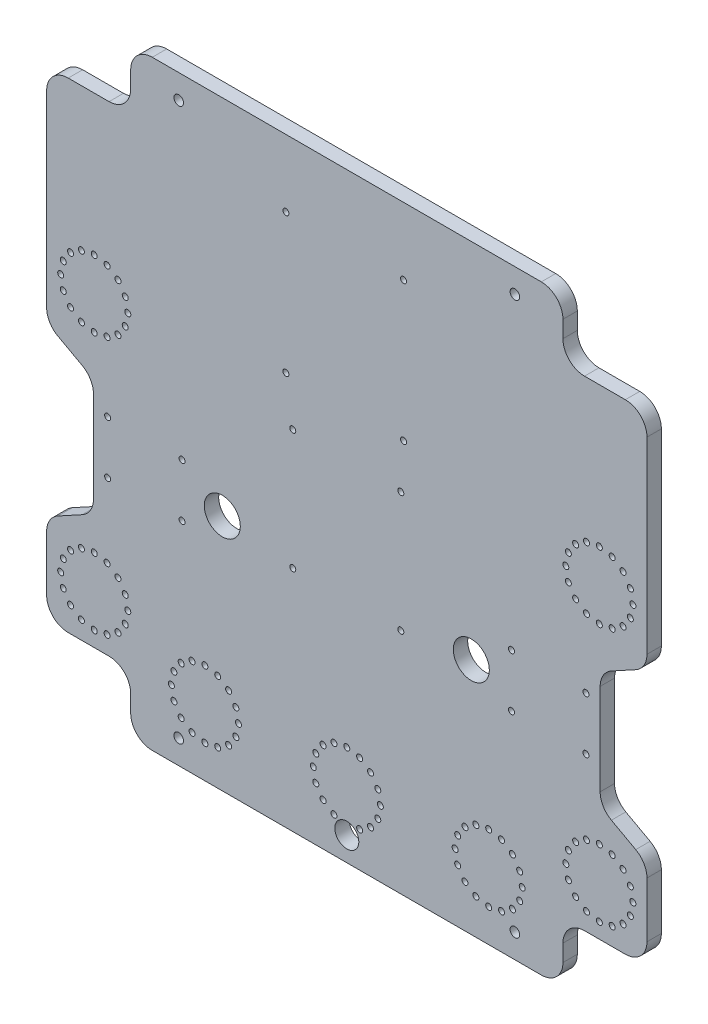
from build123d import *

# Parameters (mm, degrees)
SKETCH1_W                = 300
SKETCH1_H                = 250
BOSS_EXTRUDE1_DEPTH      = 6
SKETCH3_R                = 7.5
CUT_EXTRUDE1_DEPTH       = 391.558574352
CUT_EXTRUDE1_DEPTH_BACK  = 391.558574352
SKETCH8_R                = 1.25
ULTRASONICS_DEPTH        = 382.041008292
SKETCH6_W                = 12.5
SKETCH6_H                = 92.656290199
SKETCH6_W_2              = 35
SKETCH6_H_2              = 25
CUT_EXTRUDE3_DEPTH       = 382.041008292
SKETCH5_R                = 1.25
CUT_EXTRUDE2_DEPTH       = 372.700147969
FILLET1_R                = 9
SKETCH9_R                = 5
LIMIT_SWITCH_MOUNT_DEPTH = 372.700147969
SKETCH10_R               = 2
ALY_MOUNT_DEPTH          = 372.700147969


with BuildPart() as part:
    # Sketch1 → Boss-Extrude1 (new body)
    with BuildSketch(Plane.XY):
        with Locations((150, 125)):
            Rectangle(SKETCH1_W, SKETCH1_H)
    extrude(amount=-BOSS_EXTRUDE1_DEPTH)

    # Sketch3 → Cut-Extrude1 (cut, two sides)
    with BuildSketch(Plane.XY) as cut_extrude1_sk:
        Polygon((0, 0), (25, 0), (25, 62.343709801), (44.5, 73.000027506), (44.5, 121.687392097), (25, 132.343709801), (12.5, 132.343709801), (12.5, 225), (25, 225), (25, 250), (0, 250), align=None)
        Polygon((275, 0), (300, 0), (300, 250), (275, 250), (275, 225), (287.5, 225), (287.5, 132.343709801), (275, 132.343709801), (255.5, 121.687392097), (255.5, 73.000027506), (275, 62.343709801), align=None)
        with Locations((201.85, 99.125843129)):
            Circle(SKETCH3_R)
        with Locations((98.15, 99.125843129)):
            Circle(SKETCH3_R)
    extrude(amount=CUT_EXTRUDE1_DEPTH, mode=Mode.SUBTRACT)
    extrude(cut_extrude1_sk.sketch, amount=-CUT_EXTRUDE1_DEPTH_BACK, mode=Mode.SUBTRACT)

    # Sketch8 → Ultrasonics (cut, through all)
    with BuildSketch(Plane.XY):
        with Locations((209.09, 41.63)):
            Circle(SKETCH8_R)
        with Locations((209.09, 13.69)):
            Circle(SKETCH8_R)
        with Locations((214.43608755, 40.566597069)):
            Circle(SKETCH8_R)
        with Locations((203.74391245, 14.753402931)):
            Circle(SKETCH8_R)
        with Locations((218.968281733, 37.538281733)):
            Circle(SKETCH8_R)
        with Locations((199.211718267, 17.781718267)):
            Circle(SKETCH8_R)
        with Locations((221.996597069, 33.00608755)):
            Circle(SKETCH8_R)
        with Locations((196.183402931, 22.31391245)):
            Circle(SKETCH8_R)
        with Locations((223.06, 27.66)):
            Circle(SKETCH8_R)
        with Locations((195.12, 27.66)):
            Circle(SKETCH8_R)
        with Locations((221.996597069, 22.31391245)):
            Circle(SKETCH8_R)
        with Locations((196.183402931, 33.00608755)):
            Circle(SKETCH8_R)
        with Locations((218.968281733, 17.781718267)):
            Circle(SKETCH8_R)
        with Locations((199.211718267, 37.538281733)):
            Circle(SKETCH8_R)
        with Locations((214.43608755, 14.753402931)):
            Circle(SKETCH8_R)
        with Locations((203.74391245, 40.566597069)):
            Circle(SKETCH8_R)
        with Locations((76.94, 27.66)):
            Circle(SKETCH8_R)
        with Locations((104.88, 27.66)):
            Circle(SKETCH8_R)
        with Locations((255.16893536, 59.271223716)):
            Circle(SKETCH8_R)
        with Locations((103.816597069, 22.31391245)):
            Circle(SKETCH8_R)
        with Locations((78.003402931, 33.00608755)):
            Circle(SKETCH8_R)
        with Locations((100.788281733, 17.781718267)):
            Circle(SKETCH8_R)
        with Locations((81.031718267, 37.538281733)):
            Circle(SKETCH8_R)
        with Locations((96.25608755, 14.753402931)):
            Circle(SKETCH8_R)
        with Locations((85.56391245, 40.566597069)):
            Circle(SKETCH8_R)
        with Locations((90.91, 13.69)):
            Circle(SKETCH8_R)
        with Locations((90.91, 41.63)):
            Circle(SKETCH8_R)
        with Locations((85.56391245, 14.753402931)):
            Circle(SKETCH8_R)
        with Locations((96.25608755, 40.566597069)):
            Circle(SKETCH8_R)
        with Locations((81.031718267, 17.781718267)):
            Circle(SKETCH8_R)
        with Locations((100.788281733, 37.538281733)):
            Circle(SKETCH8_R)
        with Locations((78.003402931, 22.31391245)):
            Circle(SKETCH8_R)
        with Locations((103.816597069, 33.00608755)):
            Circle(SKETCH8_R)
        with Locations((255.16893536, 31.331223716)):
            Circle(SKETCH8_R)
        with Locations((260.51502291, 58.207820785)):
            Circle(SKETCH8_R)
        with Locations((249.82284781, 32.394626647)):
            Circle(SKETCH8_R)
        with Locations((265.047217093, 55.179505449)):
            Circle(SKETCH8_R)
        with Locations((245.290653627, 35.422941983)):
            Circle(SKETCH8_R)
        with Locations((268.075532429, 50.647311266)):
            Circle(SKETCH8_R)
        with Locations((242.262338291, 39.955136166)):
            Circle(SKETCH8_R)
        with Locations((269.13893536, 45.301223716)):
            Circle(SKETCH8_R)
        with Locations((241.19893536, 45.301223716)):
            Circle(SKETCH8_R)
        with Locations((268.075532429, 39.955136166)):
            Circle(SKETCH8_R)
        with Locations((242.262338291, 50.647311266)):
            Circle(SKETCH8_R)
        with Locations((265.047217093, 35.422941983)):
            Circle(SKETCH8_R)
        with Locations((245.290653627, 55.179505449)):
            Circle(SKETCH8_R)
        with Locations((260.51502291, 32.394626647)):
            Circle(SKETCH8_R)
        with Locations((249.82284781, 58.207820785)):
            Circle(SKETCH8_R)
        with Locations((44.83106464, 59.271223716)):
            Circle(SKETCH8_R)
        with Locations((44.83106464, 31.331223716)):
            Circle(SKETCH8_R)
        with Locations((50.17715219, 58.207820785)):
            Circle(SKETCH8_R)
        with Locations((39.48497709, 32.394626647)):
            Circle(SKETCH8_R)
        with Locations((54.709346373, 55.179505449)):
            Circle(SKETCH8_R)
        with Locations((34.952782907, 35.422941983)):
            Circle(SKETCH8_R)
        with Locations((57.737661709, 50.647311266)):
            Circle(SKETCH8_R)
        with Locations((31.924467571, 39.955136166)):
            Circle(SKETCH8_R)
        with Locations((58.80106464, 45.301223716)):
            Circle(SKETCH8_R)
        with Locations((30.86106464, 45.301223716)):
            Circle(SKETCH8_R)
        with Locations((57.737661709, 39.955136166)):
            Circle(SKETCH8_R)
        with Locations((31.924467571, 50.647311266)):
            Circle(SKETCH8_R)
        with Locations((54.709346373, 35.422941983)):
            Circle(SKETCH8_R)
        with Locations((34.952782907, 55.179505449)):
            Circle(SKETCH8_R)
        with Locations((50.17715219, 32.394626647)):
            Circle(SKETCH8_R)
        with Locations((39.48497709, 58.207820785)):
            Circle(SKETCH8_R)
        with Locations((255.16893536, 166.641143395)):
            Circle(SKETCH8_R)
        with Locations((255.16893536, 138.701143395)):
            Circle(SKETCH8_R)
        with Locations((249.82284781, 139.764546326)):
            Circle(SKETCH8_R)
        with Locations((260.51502291, 165.577740464)):
            Circle(SKETCH8_R)
        with Locations((245.290653627, 142.792861662)):
            Circle(SKETCH8_R)
        with Locations((265.047217093, 162.549425128)):
            Circle(SKETCH8_R)
        with Locations((242.262338291, 147.325055845)):
            Circle(SKETCH8_R)
        with Locations((268.075532429, 158.017230945)):
            Circle(SKETCH8_R)
        with Locations((241.19893536, 152.671143395)):
            Circle(SKETCH8_R)
        with Locations((269.13893536, 152.671143395)):
            Circle(SKETCH8_R)
        with Locations((242.262338291, 158.017230945)):
            Circle(SKETCH8_R)
        with Locations((268.075532429, 147.325055845)):
            Circle(SKETCH8_R)
        with Locations((245.290653627, 162.549425128)):
            Circle(SKETCH8_R)
        with Locations((265.047217093, 142.792861662)):
            Circle(SKETCH8_R)
        with Locations((249.82284781, 165.577740464)):
            Circle(SKETCH8_R)
        with Locations((260.51502291, 139.764546326)):
            Circle(SKETCH8_R)
        with Locations((44.83106464, 166.641143395)):
            Circle(SKETCH8_R)
        with Locations((44.83106464, 138.701143395)):
            Circle(SKETCH8_R)
        with Locations((39.48497709, 139.764546326)):
            Circle(SKETCH8_R)
        with Locations((50.17715219, 165.577740464)):
            Circle(SKETCH8_R)
        with Locations((34.952782907, 142.792861662)):
            Circle(SKETCH8_R)
        with Locations((54.709346373, 162.549425128)):
            Circle(SKETCH8_R)
        with Locations((31.924467571, 147.325055845)):
            Circle(SKETCH8_R)
        with Locations((57.737661709, 158.017230945)):
            Circle(SKETCH8_R)
        with Locations((30.86106464, 152.671143395)):
            Circle(SKETCH8_R)
        with Locations((58.80106464, 152.671143395)):
            Circle(SKETCH8_R)
        with Locations((31.924467571, 158.017230945)):
            Circle(SKETCH8_R)
        with Locations((57.737661709, 147.325055845)):
            Circle(SKETCH8_R)
        with Locations((34.952782907, 162.549425128)):
            Circle(SKETCH8_R)
        with Locations((54.709346373, 142.792861662)):
            Circle(SKETCH8_R)
        with Locations((39.48497709, 165.577740464)):
            Circle(SKETCH8_R)
        with Locations((50.17715219, 139.764546326)):
            Circle(SKETCH8_R)
        with Locations((150, 41.63)):
            Circle(SKETCH8_R)
        with Locations((150, 13.69)):
            Circle(SKETCH8_R)
        with Locations((155.34608755, 40.566597069)):
            Circle(SKETCH8_R)
        with Locations((144.65391245, 14.753402931)):
            Circle(SKETCH8_R)
        with Locations((159.878281733, 37.538281733)):
            Circle(SKETCH8_R)
        with Locations((140.121718267, 17.781718267)):
            Circle(SKETCH8_R)
        with Locations((162.906597069, 33.00608755)):
            Circle(SKETCH8_R)
        with Locations((137.093402931, 22.31391245)):
            Circle(SKETCH8_R)
        with Locations((163.97, 27.66)):
            Circle(SKETCH8_R)
        with Locations((136.03, 27.66)):
            Circle(SKETCH8_R)
        with Locations((162.906597069, 22.31391245)):
            Circle(SKETCH8_R)
        with Locations((137.093402931, 33.00608755)):
            Circle(SKETCH8_R)
        with Locations((159.878281733, 17.781718267)):
            Circle(SKETCH8_R)
        with Locations((140.121718267, 37.538281733)):
            Circle(SKETCH8_R)
        with Locations((155.34608755, 14.753402931)):
            Circle(SKETCH8_R)
        with Locations((144.65391245, 40.566597069)):
            Circle(SKETCH8_R)
    extrude(amount=-ULTRASONICS_DEPTH, mode=Mode.SUBTRACT)

    # Sketch6 → Cut-Extrude3 (cut, through all)
    with BuildSketch(Plane.XY):
        with Locations((281.25, 178.671854901)):
            Rectangle(SKETCH6_W, SKETCH6_H)
        with Locations((257.5, 237.5)):
            Rectangle(SKETCH6_W_2, SKETCH6_H_2)
        with Locations((257.5, 12.5)):
            Rectangle(SKETCH6_W_2, SKETCH6_H_2)
        with Locations((42.5, 12.5)):
            Rectangle(SKETCH6_W_2, SKETCH6_H_2)
        with Locations((42.5, 237.5)):
            Rectangle(SKETCH6_W_2, SKETCH6_H_2)
        with Locations((18.75, 178.671854901)):
            Rectangle(SKETCH6_W, SKETCH6_H)
    extrude(amount=-CUT_EXTRUDE3_DEPTH, mode=Mode.SUBTRACT)

    # Sketch5 → Cut-Extrude2 (cut, symmetric)
    with BuildSketch(Plane.XY):
        with Locations((50.4, 89.006293682)):
            Circle(SKETCH5_R)
    cut_extrude2 = extrude(amount=CUT_EXTRUDE2_DEPTH, both=True, mode=Mode.SUBTRACT)

    # Motor Mounts: Cut-Extrude2 at 15 more places
    with Locations((77.1, 5.993706, 0), (122.1, 5.993706, 0), (77.1, 55.993706, 0), (122.1, 55.993706, 0), (74.245277, 75.015797, 0), (123.245277, 75.015797, 0), (74.245277, 133.015797, 0), (123.245277, 133.015797, 0), (168.2, 21.993706, 0), (199.2, 21.993706, 0), (199.2, -0.006294, 0), (168.2, -0.006294, 0), (31, 0, 0), (31, 22, 0), (0, 22, 0)):
        add(cut_extrude2, mode=Mode.SUBTRACT)

    # Fillet1
    fillet1_edges = [part.edges().sort_by_distance(p)[0] for p in [
        (275, 62.343709801, -3),
        (255.5, 73.000027506, -3),
        (255.5, 121.687392097, -3),
        (275, 132.343709801, -3),
        (25, 132.343709801, -3),
        (44.5, 121.687392097, -3),
        (25, 25, -3),
        (60, 25, -3),
        (60, 0, -3),
        (44.5, 73.000027506, -3),
        (25, 62.343709801, -3),
        (240, 0, -3),
        (240, 25, -3),
        (275, 25, -3),
        (60, 225, -3),
        (60, 250, -3),
        (275, 225, -3),
        (240, 225, -3),
        (240, 250, -3),
        (25, 225, -3),
    ]]
    fillet(fillet1_edges, radius=FILLET1_R)

    # Sketch9 → Limit Switch mount (cut, through all)
    with BuildSketch(Plane.XY):
        with Locations((150, 10)):
            Circle(SKETCH9_R)
    extrude(amount=-LIMIT_SWITCH_MOUNT_DEPTH, mode=Mode.SUBTRACT)

    # Sketch10 → Aly mount (cut, through all)
    with BuildSketch(Plane.XY):
        with Locations((80, 240)):
            Circle(SKETCH10_R)
        with Locations((220, 240)):
            Circle(SKETCH10_R)
        with Locations((80, 10)):
            Circle(SKETCH10_R)
        with Locations((220, 10)):
            Circle(SKETCH10_R)
    extrude(amount=-ALY_MOUNT_DEPTH, mode=Mode.SUBTRACT)


solid = part.part
